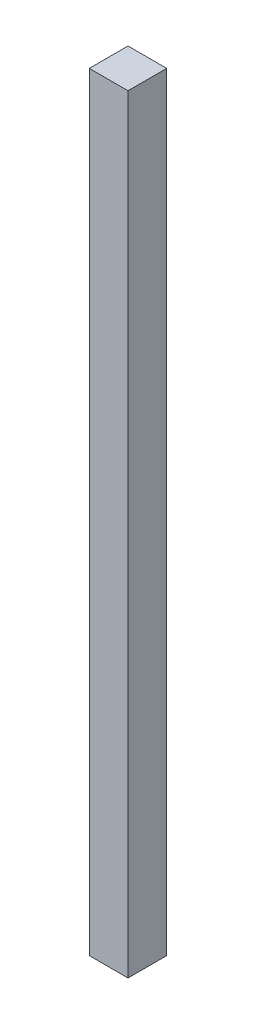
from build123d import *

# Parameters (mm, degrees)
SKETCH1_W           = 25.4
SKETCH1_H           = 25.4
BOSS_EXTRUDE1_DEPTH = 503.682


with BuildPart() as part:
    # Sketch1 → Boss-Extrude1 (new body)
    with BuildSketch(Plane(origin=(0, 0, 0), x_dir=(1, 0, 0), z_dir=(0, 1, 0))):
        with Locations((12.7, 12.7)):
            Rectangle(SKETCH1_W, SKETCH1_H)
    extrude(amount=BOSS_EXTRUDE1_DEPTH)


solid = part.part
